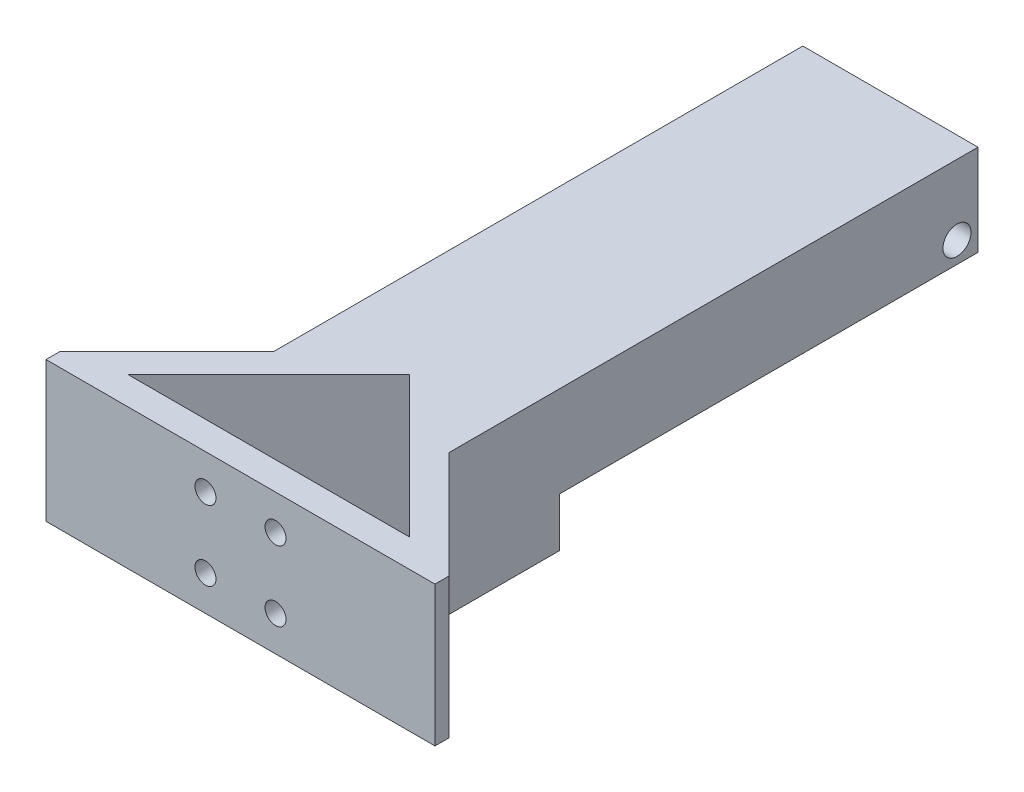
from build123d import *

# Parameters (mm, degrees)
EXTRUDE_1_DEPTH     = 20
SKETCH_2_R          = 1.5
CUT_EXTRUDE_1_DEPTH = 5
SKETCH_4_W          = 24.99770673
SKETCH_4_H          = 59.73
CUT_EXTRUDE_3_DEPTH = 7
SKETCH_8_R          = 2
CUT_EXTRUDE_5_DEPTH = 41.24770673


with BuildPart() as part:
    # 스케치1 → 보스-돌출1 (new body)
    with BuildSketch(Plane(origin=(0, 0, 0), x_dir=(1, 0, 0), z_dir=(0, 1, 0))):
        Polygon((40.24770673, 92.73229327), (15.25229327, 92.73229327), (15.25229327, 17.25229327), (0, 2), (0, 0), (55.5, 0), (55.5, 2), (40.24770673, 17.25229327), align=None)
        Polygon((27.75, 24.093145751), (47.843145751, 4), (7.656854249, 4), align=None, mode=Mode.SUBTRACT)
    extrude(amount=EXTRUDE_1_DEPTH)

    # 스케치2 → 컷-돌출1 (cut)
    with BuildSketch(Plane.XY):
        with Locations((22.75, 15)):
            Circle(SKETCH_2_R)
        with Locations((32.75, 15)):
            Circle(SKETCH_2_R)
        with Locations((32.75, 5)):
            Circle(SKETCH_2_R)
        with Locations((22.75, 5)):
            Circle(SKETCH_2_R)
    extrude(amount=-CUT_EXTRUDE_1_DEPTH, mode=Mode.SUBTRACT)

    # 스케치4 → 컷-돌출3 (cut)
    with BuildSketch(Plane.XZ):
        with Locations((27.748853365, -62.86729327)):
            Rectangle(SKETCH_4_W, SKETCH_4_H)
    extrude(amount=-CUT_EXTRUDE_3_DEPTH, mode=Mode.SUBTRACT)

    # 스케치8 → 컷-돌출5 (cut, through all)
    with BuildSketch(Plane.ZY.offset(-15.25229327)):
        with Locations((-89.73229327, 10)):
            Circle(SKETCH_8_R)
    extrude(amount=-CUT_EXTRUDE_5_DEPTH, mode=Mode.SUBTRACT)


solid = part.part
